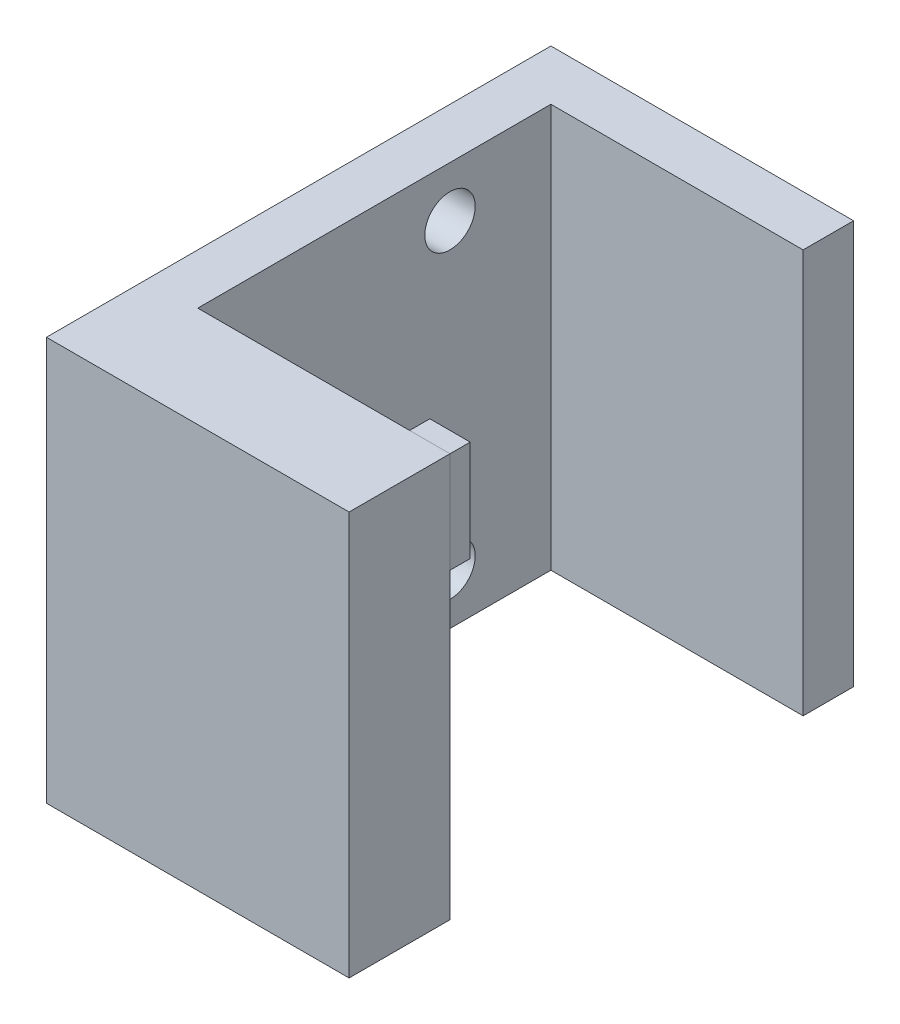
from build123d import *

# Parameters (mm, degrees)
BOSS_EXTRUDE1_DEPTH = 200
HOLE1_D             = 25
SKETCH4_W           = 20
SKETCH4_H           = 50
BOSS_EXTRUDE2_DEPTH = 10


with BuildPart() as part:
    # Sketch1 → Boss-Extrude1 (new body)
    with BuildSketch(Plane(origin=(0, 0, 0), x_dir=(1, 0, 0), z_dir=(0, 1, 0))):
        Polygon((0, 225), (0, 250), (-150, 250), (-150, 0), (0, 0), (0, 50), (-125, 50), (-125, 225), align=None)
    extrude(amount=BOSS_EXTRUDE1_DEPTH)

    # Hole1 (through all)
    with Locations(Plane(origin=(-150, 175, -175), x_dir=(0, 0, -1), z_dir=(-1, 0, 0))):
        with Locations((0, 0), (0, 150)):
            Hole(HOLE1_D / 2)


with BuildPart() as body_2:
    # Sketch4 → Boss-Extrude2 (new body)
    with BuildSketch(Plane(origin=(0, 0, -50), x_dir=(-1, 0, 0), z_dir=(0, 0, -1))):
        with Locations((10, 175)):
            Rectangle(SKETCH4_W, SKETCH4_H)
    extrude(amount=BOSS_EXTRUDE2_DEPTH)


solid = Compound([part.part, body_2.part])
